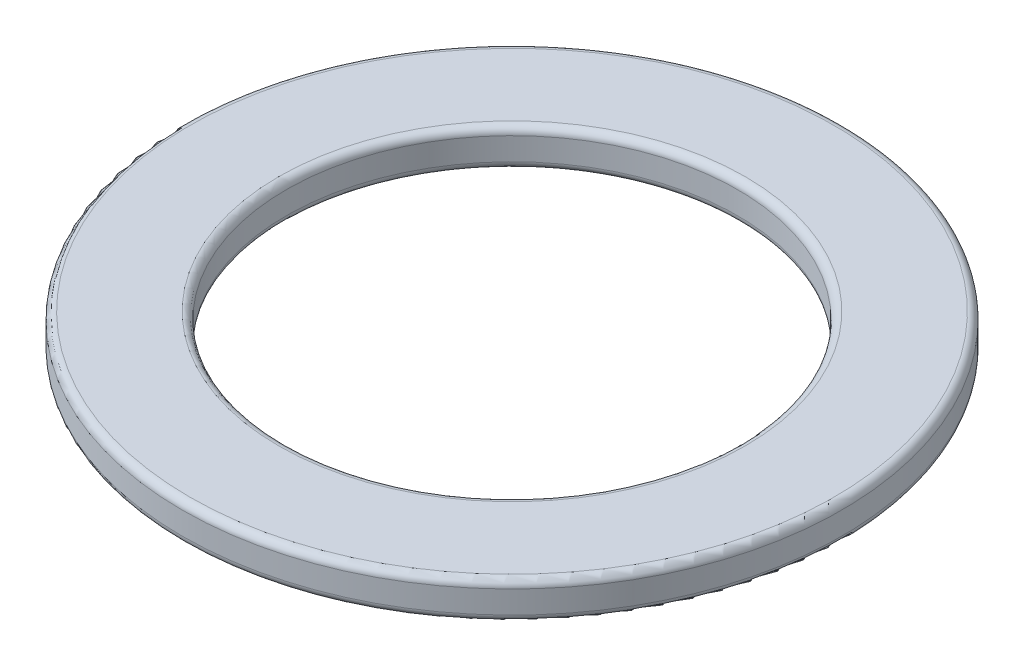
from build123d import *

# Parameters (mm, degrees)
SKETCH2_R           = 4.38
SKETCH2_R_2         = 3
BOSS_EXTRUDE1_DEPTH = 0.5
FILLET1_R           = 0.1


with BuildPart() as part:
    # Sketch2 → Boss-Extrude1 (new body)
    with BuildSketch(Plane(origin=(0, 0, 0), x_dir=(1, 0, 0), z_dir=(0, 1, 0))):
        Circle(SKETCH2_R)
        Circle(SKETCH2_R_2, mode=Mode.SUBTRACT)
    extrude(amount=BOSS_EXTRUDE1_DEPTH)

    # Fillet1
    fillet1_edges = [part.edges().sort_by_distance(p)[0] for p in [
        (-4.38, 0, 0),
        (-4.38, 0.5, 0),
        (-3, 0, 0),
        (-3, 0.5, 0),
    ]]
    fillet(fillet1_edges, radius=FILLET1_R)


solid = part.part
